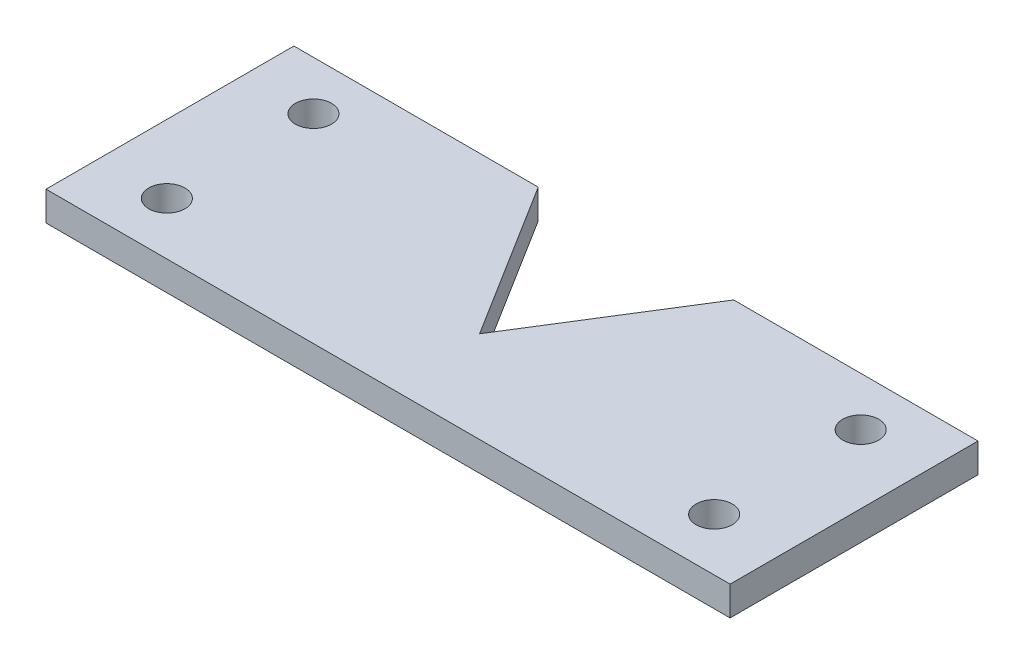
from build123d import *

# Parameters (mm, degrees)
AUFSATZ_LINEAR_AUSTRAGEN1_DEPTH    = 40
DURCHGANGSLOCH_F_R_M81_D           = 8.4
DURCHGANGSLOCH_F_R_M3_51_D         = 3.7
DURCHGANGSLOCH_F_R_M82_D           = 8.4
DURCHGANGSLOCH_F_R_M82_CSINK_D     = 8.45
DURCHGANGSLOCH_F_R_M82_CSINK_ANGLE = 90
SKIZZE21_R                         = 5
SCHNITT_LINEAR_AUSTRAGEN1_DEPTH    = 12
SKIZZE22_W                         = 70
SKIZZE22_H                         = 14.633500803
SCHNITT_LINEAR_AUSTRAGEN2_DEPTH    = 20
SKIZZE23_W                         = 70
SKIZZE23_H                         = 15
SCHNITT_LINEAR_AUSTRAGEN3_DEPTH    = 26
SKIZZE25_W                         = 70
SKIZZE25_H                         = 2
SCHNITT_LINEAR_AUSTRAGEN5_DEPTH    = 26
SCHNITT_LINEAR_AUSTRAGEN6_DEPTH    = 3


with BuildPart() as part:
    # Skizze1 → Aufsatz-Linear austragen1 (new body)
    with BuildSketch(Plane.XY):
        Polygon((-85.072105864, 34.368747103), (-85.072105864, 14.368747103), (-50.072105864, 14.368747103), (-50.072105864, 28.368747103), (-65.805439197, 28.368747103), (-65.805439197, 34.368747103), align=None)
        Polygon((-50.072105864, 28.368747103), (-50.072105864, 14.368747103), (-15.072105864, 14.368747103), (-15.072105864, 34.368747103), (-34.33877253, 34.368747103), (-34.33877253, 28.368747103), align=None)
    extrude(amount=AUFSATZ_LINEAR_AUSTRAGEN1_DEPTH)

    # Durchgangsloch für M81 (through all)
    with Locations(Plane(origin=(0, 34.368747103, 0), x_dir=(1, 0, 0), z_dir=(0, 1, 0))):
        with Locations((-78.072105864, -33), (-22.072105864, -33)):
            Hole(DURCHGANGSLOCH_F_R_M81_D / 2)

    # Durchgangsloch für M3.51 (through all)
    with Locations(Plane(origin=(0, 34.368747103, 0), x_dir=(1, 0, 0), z_dir=(0, 1, 0))):
        with Locations((-78.072105864, -5), (-78.072105864, -20), (-22.072105864, -20), (-22.072105864, -5)):
            Hole(DURCHGANGSLOCH_F_R_M3_51_D / 2)

    # Durchgangsloch für M82 (through all)
    with Locations(Plane(origin=(0, 14.368747103, 0), x_dir=(-1, 0, 0), z_dir=(0, -1, 0))):
        with Locations((50.072105864, -33)):
            CounterSinkHole(DURCHGANGSLOCH_F_R_M82_D / 2, DURCHGANGSLOCH_F_R_M82_CSINK_D / 2, counter_sink_angle=DURCHGANGSLOCH_F_R_M82_CSINK_ANGLE)

    # Skizze21 → Schnitt-Linear austragen1 (cut)
    with BuildSketch(Plane(origin=(0, 28.368747103, 0), x_dir=(1, 0, 0), z_dir=(0, 1, 0))):
        with Locations((-50.072105864, -33)):
            Circle(SKIZZE21_R)
    extrude(amount=-SCHNITT_LINEAR_AUSTRAGEN1_DEPTH, mode=Mode.SUBTRACT)

    # Skizze22 → Schnitt-Linear austragen2 (cut)
    with BuildSketch(Plane(origin=(0, 34.368747103, 0), x_dir=(1, 0, 0), z_dir=(0, 1, 0))):
        with Locations((-50.072105864, -32.683249598)):
            Rectangle(SKIZZE22_W, SKIZZE22_H)
    extrude(amount=-SCHNITT_LINEAR_AUSTRAGEN2_DEPTH, mode=Mode.SUBTRACT)

    # Skizze23 → Schnitt-Linear austragen3 (cut)
    with BuildSketch(Plane(origin=(0, 0, 0), x_dir=(-1, 0, 0), z_dir=(0, 0, -1))):
        with Locations((50.072105864, 26.868747103)):
            Rectangle(SKIZZE23_W, SKIZZE23_H)
    extrude(amount=-SCHNITT_LINEAR_AUSTRAGEN3_DEPTH, mode=Mode.SUBTRACT)

    # Skizze25 → Schnitt-Linear austragen5 (cut)
    with BuildSketch(Plane.XY.offset(25.366499197)):
        with Locations((-50.072105864, 15.368747103)):
            Rectangle(SKIZZE25_W, SKIZZE25_H)
    extrude(amount=-SCHNITT_LINEAR_AUSTRAGEN5_DEPTH, mode=Mode.SUBTRACT)

    # Skizze26 → Schnitt-Linear austragen6 (cut)
    with BuildSketch(Plane.XZ.offset(-16.368747103)):
        Polygon((-40.072105864, 0), (-50.072105864, 16), (-60.072105864, 0), align=None)
    extrude(amount=-SCHNITT_LINEAR_AUSTRAGEN6_DEPTH, mode=Mode.SUBTRACT)


solid = part.part
